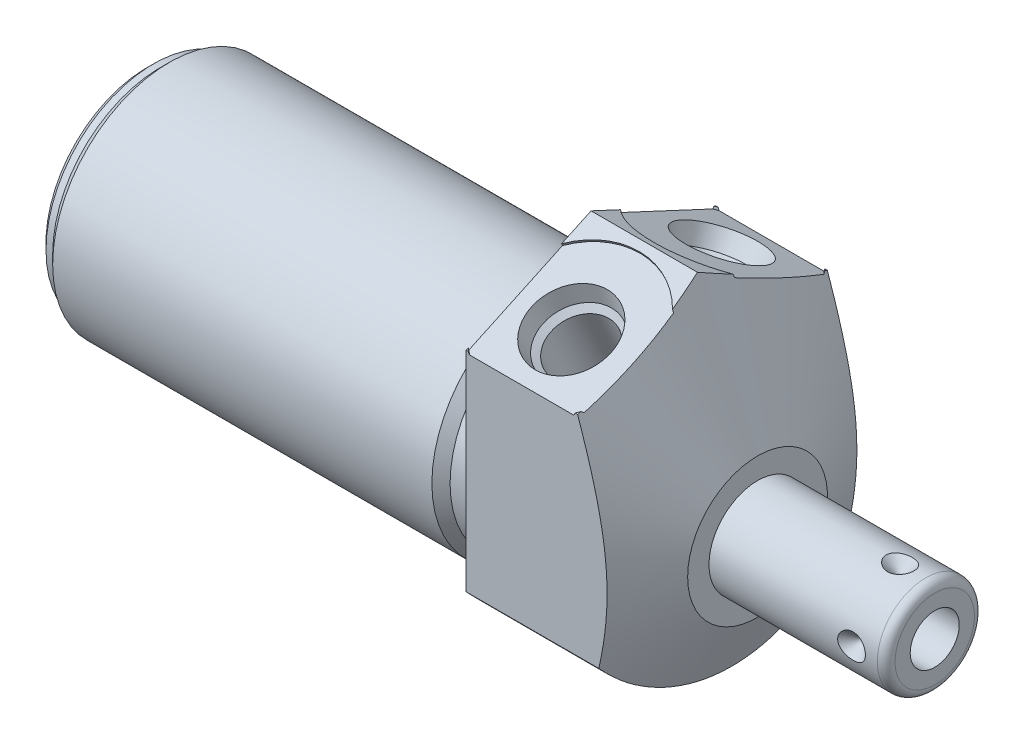
from build123d import *

# Parameters (mm, degrees)
SKETCH1_R           = 19.05
EXTRUDE1_DEPTH      = 19.05
EXTRUDE1_DEPTH_BACK = 50.8
CUT_EXTRUDE1_REACH  = 52.8
SKETCH2_R           = 19.05
SKETCH2_R_2         = 13.3604
CUT_EXTRUDE3_REACH  = 21.05
SKETCH19_R          = 8.6614
CUT_EXTRUDE4_DEPTH  = 0.254
SKETCH20_R          = 8.6614
CUT_EXTRUDE5_DEPTH  = 0.254
CHAMFER1_SIZE       = 0.762
CIRPATTERN1_COUNT   = 4


with BuildPart() as part:
    # Sketch1 → Extrude1 (new body, two sides)
    with BuildSketch(Plane(origin=(0, 0, 0), x_dir=(0, 0, -1), z_dir=(1, 0, 0))) as extrude1_sk:
        Circle(SKETCH1_R)
    extrude(amount=EXTRUDE1_DEPTH)
    extrude(extrude1_sk.sketch, amount=-EXTRUDE1_DEPTH_BACK)

    # Sketch2 → Cut-Extrude1 (cut, up to next)
    with BuildSketch(Plane(origin=(0, 0, 0), x_dir=(0, 0, -1), z_dir=(1, 0, 0)), mode=Mode.PRIVATE) as cut_extrude1_sk1:
        Circle(SKETCH2_R)
        with Locations((0, -4.7498)):
            Circle(SKETCH2_R_2, mode=Mode.SUBTRACT)
    cut_extrude1_tool1 = extrude(cut_extrude1_sk1.sketch, amount=-CUT_EXTRUDE1_REACH, mode=Mode.PRIVATE) & part.part
    add(cut_extrude1_tool1.solids().sort_by_distance((0, 0, 18.511185))[0], mode=Mode.SUBTRACT)

    # Sketch4 → Cut-Extrude3 (cut, up to next)
    with BuildSketch(Plane.ZY, mode=Mode.PRIVATE) as cut_extrude3_sk1:
        with BuildLine():
            Line((14.2875, -12.600390619), (14.2875, 11.344778237))
            Line((14.2875, 11.344778237), (0, 18.007148903))
            Line((0, 18.007148903), (-14.2875, 11.344778237))
            Line((-14.2875, 11.344778237), (-14.2875, -12.600390619))
            ThreePointArc((-14.2875, -12.600390619), (0, 19.05), (14.2875, -12.600390619))
        make_face()
    cut_extrude3_tool1 = extrude(cut_extrude3_sk1.sketch, amount=-CUT_EXTRUDE3_REACH, mode=Mode.PRIVATE) & part.part
    add(cut_extrude3_tool1.solids().sort_by_distance((0, -0.627806, 14.782814))[0], mode=Mode.SUBTRACT)

    # Sketch6 → Cut-Revolve2 (revolve, cut)
    with BuildSketch(Plane.XY, mode=Mode.PRIVATE) as cut_revolve2_sk:
        Polygon((12.169188023, 18.007148903), (19.05, 3.2512), (19.05, 18.007148903), align=None)
    revolve(cut_revolve2_sk.sketch.rotate(Axis((1.987224567, -4.7498, 0), (1, 0, 0)), 270), axis=Axis((1.987224567, -4.7498, 0), (1, 0, 0)), mode=Mode.SUBTRACT)  # turned: the seam where the file's is

    # S2D0002 → Cut-Revolve3 (revolve, cut)
    with BuildSketch(Plane(origin=(6.35, 13.712414668, 8.609072086), x_dir=(0, 0.422618262, -0.906307787), z_dir=(1, 0, 0))):
        Polygon((0, 0), (4.5466, 0), (4.106586662, -2.0701), (3.4544, -2.722286662), (3.4544, -12.192), (0, -12.192), align=None)
    revolve(axis=Axis((6.35, 2.110224902, 3.198882147), (0, 0.906307787, 0.422618262)), mode=Mode.SUBTRACT)

    # Sketch19 → Cut-Extrude4 (cut)
    with BuildSketch(Plane(origin=(0, 14.790960552, 6.897138177), x_dir=(1, 0, 0), z_dir=(0, 0.906307787, 0.422618262))):
        with Locations((6.35, -2.00735222)):
            Circle(SKETCH19_R)
    extrude(amount=-CUT_EXTRUDE4_DEPTH, mode=Mode.SUBTRACT)

    # Sketch8 → Cut-Revolve4 (revolve, cut)
    with BuildSketch(Plane(origin=(6.35, 13.712414668, -8.609072086), x_dir=(0, -0.422618262, -0.906307787), z_dir=(1, 0, 0))):
        Polygon((0, 0), (4.5466, 0), (4.106586662, -2.0701), (3.4544, -2.722286662), (3.4544, -12.192), (0, -12.192), align=None)
    revolve(axis=Axis((6.35, 2.110224902, -3.198882147), (0, 0.906307787, -0.422618262)), mode=Mode.SUBTRACT)

    # Sketch20 → Cut-Extrude5 (cut)
    with BuildSketch(Plane(origin=(0, 14.790960552, -6.897138177), x_dir=(1, 0, 0), z_dir=(0, 0.906307787, -0.422618262))):
        with Locations((6.35, 2.00735222)):
            Circle(SKETCH20_R)
    extrude(amount=-CUT_EXTRUDE5_DEPTH, mode=Mode.SUBTRACT)

    # Sketch10 → Cut-Revolve6 (revolve, cut)
    with BuildSketch(Plane.XY, mode=Mode.PRIVATE) as cut_revolve6_sk:
        Polygon((0, 8.6106), (0, 7.5692), (-3.81, 7.5692), (-4.8514, 8.6106), align=None)
    revolve(cut_revolve6_sk.sketch.rotate(Axis((-5.09397, -4.7498, 0), (1, 0, 0)), 90), axis=Axis((-5.09397, -4.7498, 0), (1, 0, 0)), mode=Mode.SUBTRACT)  # turned: the seam where the file's is

    # Sketch12 → Cut-Revolve8 (revolve, cut)
    with BuildSketch(Plane.XY, mode=Mode.PRIVATE) as cut_revolve8_sk:
        Polygon((-50.8, 8.6106), (-50.8, 7.5692), (-49.276, 7.5692), (-48.2346, 8.6106), align=None)
    revolve(cut_revolve8_sk.sketch.rotate(Axis((-50.92827, -4.7498, 0), (1, 0, 0)), 90), axis=Axis((-50.92827, -4.7498, 0), (1, 0, 0)), mode=Mode.SUBTRACT)  # turned: the seam where the file's is

    # Chamfer1
    chamfer1_edges = [part.edges().sort_by_distance(p)[0] for p in [
        (-50.8, -4.7498, -12.319),
    ]]
    chamfer(chamfer1_edges, length=CHAMFER1_SIZE)

    # Sketch13 → Revolve1 (revolve)
    with BuildSketch(Plane(origin=(0, 0, 0), x_dir=(0, -1, 0), z_dir=(0, 0, 1)), mode=Mode.PRIVATE) as revolve1_sk:
        with BuildLine():
            Line((4.7498, 19.05), (4.7498, 39.3192))
            Line((4.7498, 39.3192), (9.29005, 39.3192))
            ThreePointArc((9.29005, 39.3192), (10.00847049, 39.02162049), (10.30605, 38.3032))
            Line((10.30605, 38.3032), (10.30605, 19.05))
            Line((10.30605, 19.05), (4.7498, 19.05))
        make_face()
    revolve(revolve1_sk.sketch.rotate(Axis((18.03654, -4.7498, 0), (1, 0, 0)), 270), axis=Axis((18.03654, -4.7498, 0), (1, 0, 0)))  # turned: the seam where the file's is

    # S2D0001 → Cut-Revolve9 (revolve, cut)
    with BuildSketch(Plane(origin=(39.3192, -7.5565, 0), x_dir=(0, -1, 0), z_dir=(0, 0, 1)), mode=Mode.PRIVATE) as cut_revolve9_sk:
        Polygon((0, 0), (0, -10.16), (-2.8067, -11.846435499), (-2.8067, 0), align=None)
    revolve(cut_revolve9_sk.sketch.rotate(Axis((26.880442726, -4.7498, 0), (1, 0, 0)), 270), axis=Axis((26.880442726, -4.7498, 0), (1, 0, 0)), mode=Mode.SUBTRACT)  # turned: the seam where the file's is

    # Sketch16 → Cut-Revolve10 (revolve, cut)
    with BuildSketch(Plane(origin=(35.3568, 2.197634211, 0), x_dir=(-1, 0, 0), z_dir=(0, 0, -1)), mode=Mode.PRIVATE) as cut_revolve10_sk:
        Polygon((0, -1.391184211), (1.5875, -1.391184211), (0, -2.978684211), align=None)
    cut_revolve10 = revolve(cut_revolve10_sk.sketch.rotate(Axis((35.3568, -1.281162177, 0), (0, 1, 0)), 90), axis=Axis((35.3568, -1.281162177, 0), (0, 1, 0)), mode=Mode.SUBTRACT)  # turned: the seam where the file's is

    # CirPattern1: Cut-Revolve10 ×4 about axis
    cirpattern1_axis = Axis((18.03654, -4.7498, 0), (-1, 0, 0))
    for i in range(1, CIRPATTERN1_COUNT):
        add(cut_revolve10.rotate(cirpattern1_axis, i * 360 / CIRPATTERN1_COUNT), mode=Mode.SUBTRACT)


solid = part.part
